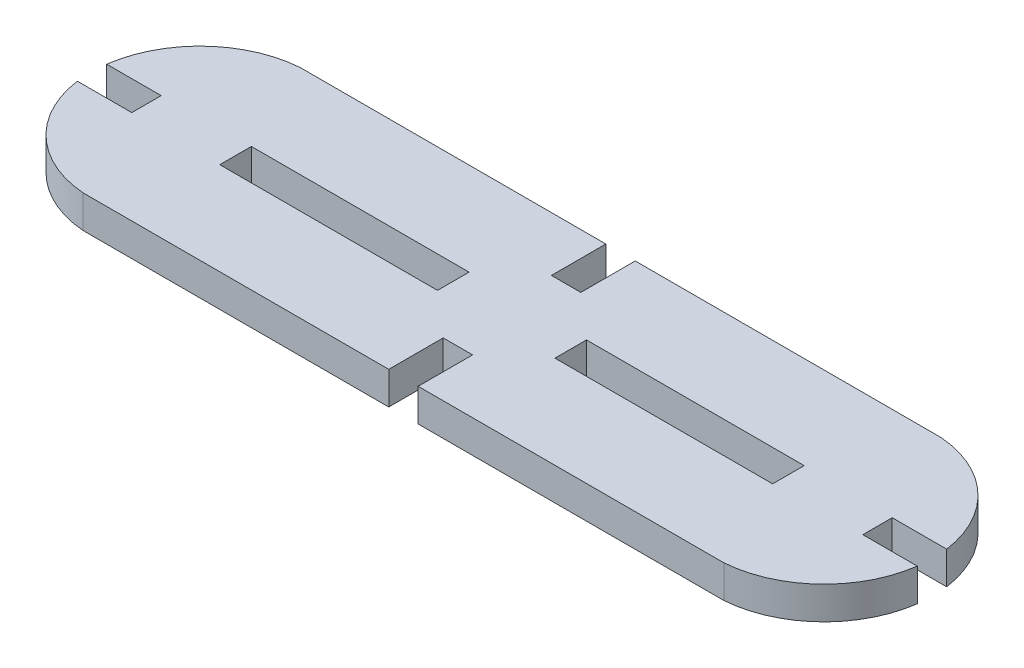
from build123d import *

# Parameters (mm, degrees)
BOSS_EXTRUDE1_DEPTH = 3
CUT_EXTRUDE1_REACH  = 5
SKETCH2_W           = 20
SKETCH2_H           = 2.9


with BuildPart() as part:
    # Sketch1 → Boss-Extrude1 (new body)
    with BuildSketch(Plane(origin=(0, 0, 0), x_dir=(1, 0, 0), z_dir=(0, 1, 0))):
        with BuildLine():
            Line((-50, 30), (-21.914, 30))
            Line((-21.914, 30), (-21.914, 25))
            Line((-21.914, 25), (-19.214, 25))
            Line((-19.214, 25), (-19.214, 30))
            Line((-19.214, 30), (8.872, 30))
            ThreePointArc((8.872, 30), (14.965992065, 27.304879145), (18.013850136, 21.379427525))
            Line((18.013850136, 21.379427525), (13.013850136, 21.379427525))
            Line((13.013850136, 21.379427525), (13.013850136, 18.679427525))
            Line((13.013850136, 18.679427525), (18.013850136, 18.679427525))
            ThreePointArc((18.013850136, 18.679427525), (14.965992065, 12.753975906), (8.872, 10.058855051))
            Line((8.872, 10.058855051), (-19.214, 10.058855051))
            Line((-19.214, 10.058855051), (-19.214, 15.058855051))
            Line((-19.214, 15.058855051), (-21.914, 15.058855051))
            Line((-21.914, 15.058855051), (-21.914, 10.058855051))
            Line((-21.914, 10.058855051), (-50, 10.058855051))
            ThreePointArc((-50, 10.058855051), (-56.093992065, 12.753975906), (-59.141850136, 18.679427525))
            Line((-59.141850136, 18.679427525), (-54.141850136, 18.679427525))
            Line((-54.141850136, 18.679427525), (-54.141850136, 21.379427525))
            Line((-54.141850136, 21.379427525), (-59.141850136, 21.379427525))
            ThreePointArc((-59.141850136, 21.379427525), (-56.093992065, 27.304879145), (-50, 30))
        make_face()
    extrude(amount=BOSS_EXTRUDE1_DEPTH)

    # Sketch2 → Cut-Extrude1 (cut, up to next)
    with BuildSketch(Plane(origin=(0, 3, 0), x_dir=(1, 0, 0), z_dir=(0, 1, 0)), mode=Mode.PRIVATE) as cut_extrude1_sk1:
        with Locations((-35.957, 20.029427525)):
            Rectangle(SKETCH2_W, SKETCH2_H)
    cut_extrude1_tool1 = extrude(cut_extrude1_sk1.sketch, amount=-CUT_EXTRUDE1_REACH, mode=Mode.PRIVATE) & part.part
    add(cut_extrude1_tool1.solids().sort_by_distance((-35.957, 3, -20.029428))[0], mode=Mode.SUBTRACT)
    # Sketch2 → Cut-Extrude1 (cut, up to next)
    with BuildSketch(Plane(origin=(0, 3, 0), x_dir=(1, 0, 0), z_dir=(0, 1, 0)), mode=Mode.PRIVATE) as cut_extrude1_sk2:
        with Locations((-5.171, 20.029427525)):
            Rectangle(SKETCH2_W, SKETCH2_H)
    cut_extrude1_tool2 = extrude(cut_extrude1_sk2.sketch, amount=-CUT_EXTRUDE1_REACH, mode=Mode.PRIVATE) & part.part
    add(cut_extrude1_tool2.solids().sort_by_distance((-5.171, 3, -20.029428))[0], mode=Mode.SUBTRACT)


solid = part.part
